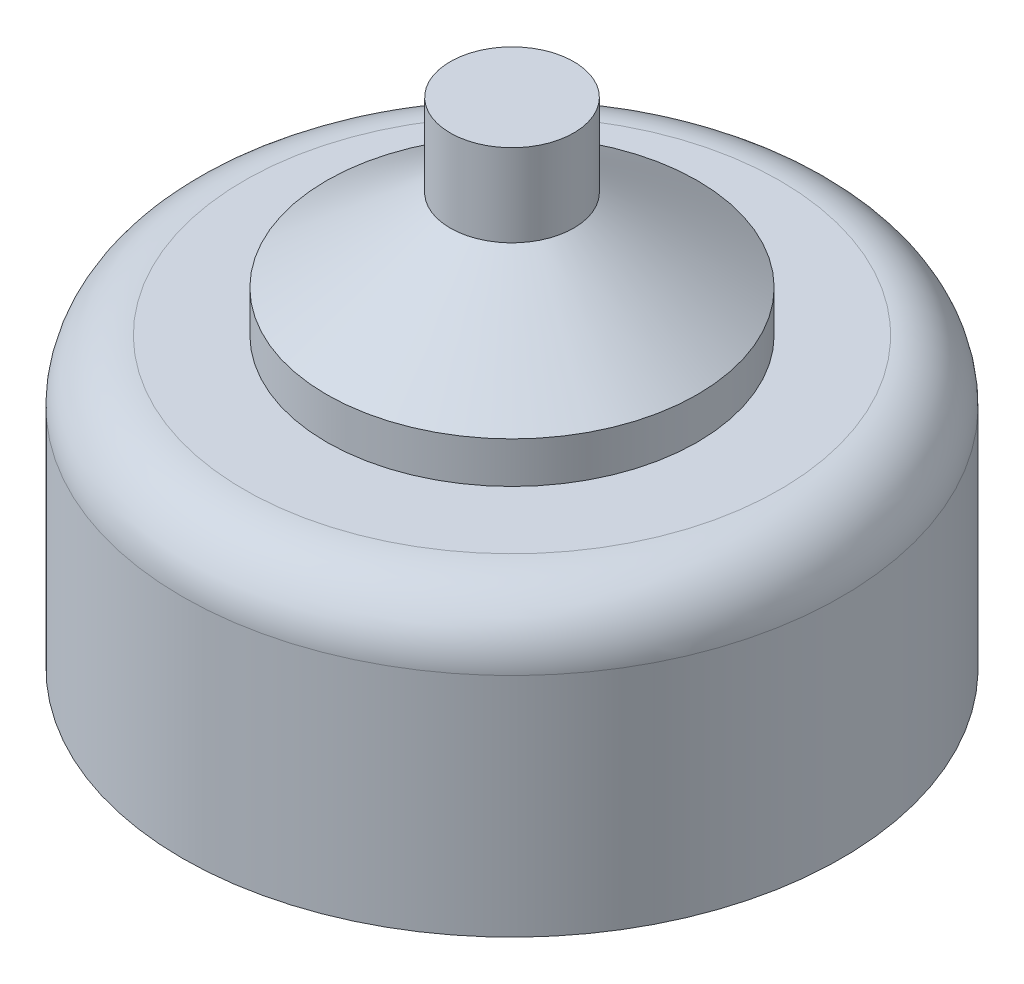
from build123d import *

# Parameters (mm, degrees)
FILLET2_R = 1.5


with BuildPart() as part:
    # Sketch2 → Revolve1 (revolve)
    with BuildSketch(Plane.XY):
        Polygon((0, -30.015007431), (8, -30.015007431), (8, -23.015007431), (4.5, -23.015007431), (4.5, -22.015007431), (1.5, -20.015007431), (1.5, -18.015007431), (0, -18.015007431), align=None)
    revolve(axis=Axis((0, 46.076216781, 0), (0, -1, 0)))

    # Fillet2
    fillet2_edges = [part.edges().sort_by_distance(p)[0] for p in [
        (-8, -23.015007431, 0),
    ]]
    fillet(fillet2_edges, radius=FILLET2_R)


solid = part.part
